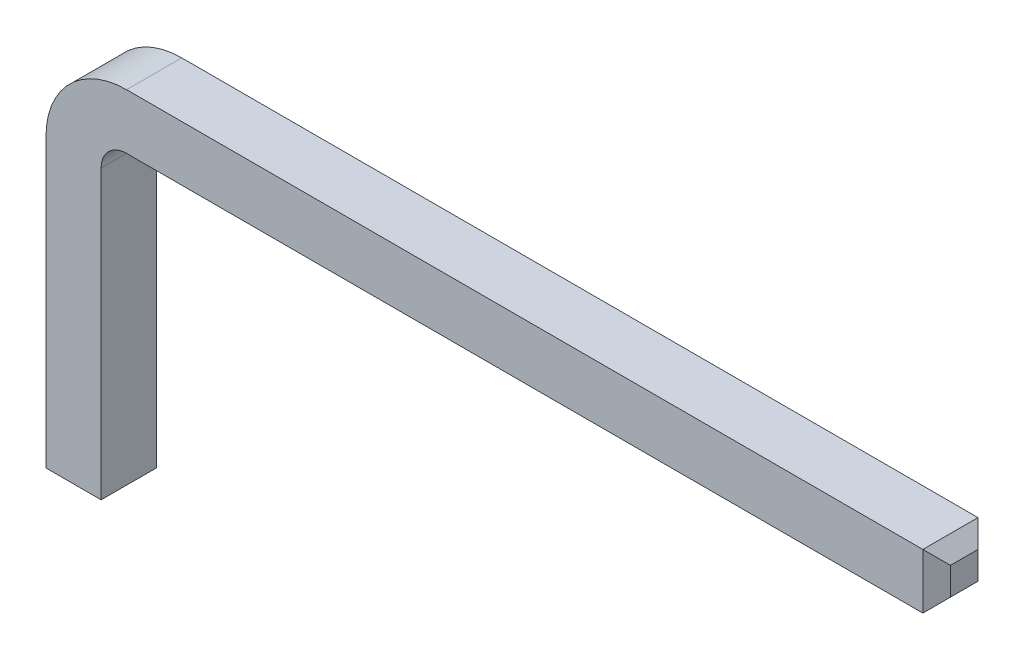
from build123d import *

# Parameters (mm, degrees)
BODY_DEPTH     = 0.65
CHAMFER_2_SIZE = 0.1625


with BuildPart() as part:
    # Sketch1 → Body (new body)
    with BuildSketch(Plane.XY):
        with BuildLine():
            Line((0, 3.55), (0, 0))
            Line((0, 0), (0.65, 0))
            Line((0.65, 0), (0.65, 3.55))
            ThreePointArc((0.65, 3.55), (0.737867966, 3.762132034), (0.95, 3.85))
            Line((0.95, 3.85), (10.5, 3.85))
            Line((10.5, 3.85), (10.5, 4.5))
            Line((10.5, 4.5), (0.95, 4.5))
            ThreePointArc((0.95, 4.5), (0.278248558, 4.221751442), (0, 3.55))
        make_face()
    extrude(amount=BODY_DEPTH)

    # Chamfer 2
    chamfer_2_edges = [part.edges().sort_by_distance(p)[0] for p in [
        (0, 0, 0.325),
        (0.65, 0, 0.325),
        (0.325, 0, 0),
        (0.325, 0, 0.65),
        (10.5, 3.85, 0.325),
        (10.5, 4.5, 0.325),
        (10.5, 4.175, 0),
        (10.5, 4.175, 0.65),
    ]]
    chamfer(chamfer_2_edges, length=CHAMFER_2_SIZE)


solid = part.part
